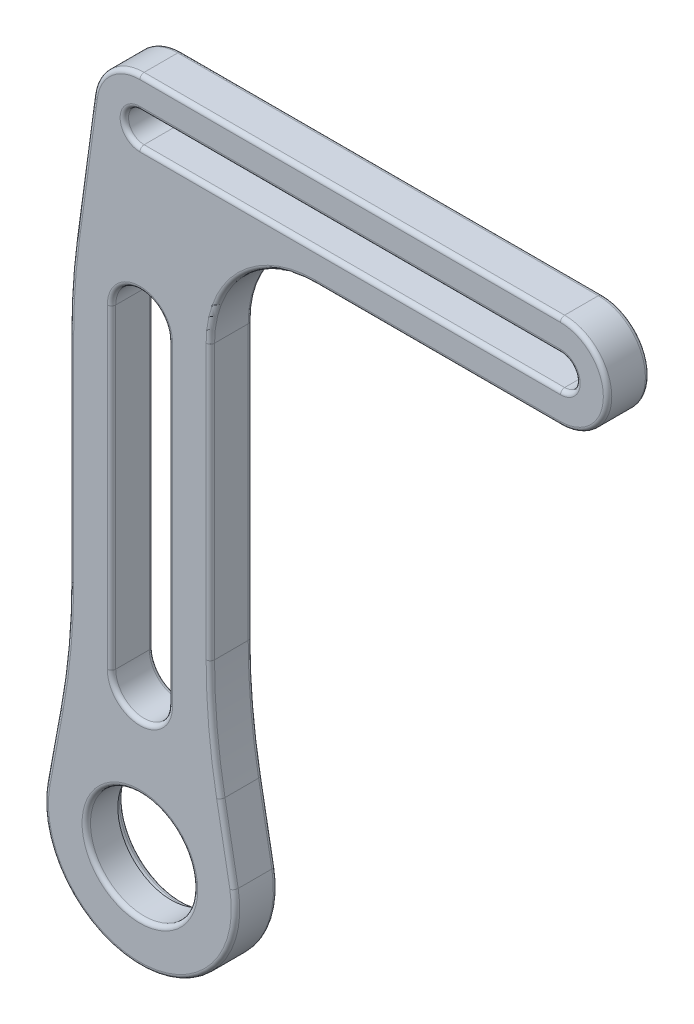
from build123d import *

# Parameters (mm, degrees)
SKETCH1_R                = 6.477
BOSS_EXTRUDE1_DEPTH      = 3.81
BOSS_EXTRUDE1_DEPTH_BACK = 1.27
SKETCH2_R                = 7.0739
CUT_EXTRUDE1_DEPTH       = 2.27
FILLET2_R                = 12.7
FILLET3_R                = 76.2
FILLET1_R                = 0.508


with BuildPart() as part:
    # Sketch1 → Boss-Extrude1 (new body, two sides)
    with BuildSketch(Plane.XY) as boss_extrude1_sk:
        with BuildLine():
            Line((-19.304, 30.32662374), (-19.304, -7.77337626))
            Line((-19.304, -7.77337626), (-22.161362566, -23.309533302))
            ThreePointArc((-22.161362566, -23.309533302), (-10.795, -36.957), (0.571362566, -23.309533302))
            Line((0.571362566, -23.309533302), (-2.286, -7.77337626))
            Line((-2.286, -7.77337626), (-2.286, 30.32662374))
            Line((-2.286, 30.32662374), (-2.286, 44.9973954))
            Line((-2.286, 44.9973954), (40.005, 44.9973954))
            ThreePointArc((40.005, 44.9973954), (45.6946, 50.6869954), (40.005, 56.3765954))
            Line((40.005, 56.3765954), (-10.795, 56.3765954))
            ThreePointArc((-10.795, 56.3765954), (-14.537468296, 54.972491779), (-16.432772192, 51.45320221))
            Line((-16.432772192, 51.45320221), (-19.304, 30.32662374))
        make_face()
        with Locations((-10.795, -25.4)):
            Circle(SKETCH1_R, mode=Mode.SUBTRACT)
        with BuildLine():
            ThreePointArc((-7.366, -7.77337626), (-10.795, -11.20237626), (-14.224, -7.77337626))
            Line((-14.224, -7.77337626), (-14.224, 30.32662374))
            ThreePointArc((-14.224, 30.32662374), (-10.795, 33.75562374), (-7.366, 30.32662374))
            Line((-7.366, 30.32662374), (-7.366, -7.77337626))
        make_face(mode=Mode.SUBTRACT)
        with BuildLine():
            ThreePointArc((-10.795, 48.8073954), (-12.6746, 50.6869954), (-10.795, 52.5665954))
            Line((-10.795, 52.5665954), (40.005, 52.5665954))
            ThreePointArc((40.005, 52.5665954), (41.8846, 50.6869954), (40.005, 48.8073954))
            Line((40.005, 48.8073954), (-10.795, 48.8073954))
        make_face(mode=Mode.SUBTRACT)
    extrude(amount=BOSS_EXTRUDE1_DEPTH)
    extrude(boss_extrude1_sk.sketch, amount=-BOSS_EXTRUDE1_DEPTH_BACK)

    # Sketch2 → Cut-Extrude1 (cut, through all)
    with BuildSketch(Plane.XY):
        with Locations((-10.795, -25.4)):
            Circle(SKETCH2_R)
    extrude(amount=-CUT_EXTRUDE1_DEPTH, mode=Mode.SUBTRACT)

    # Fillet2
    fillet2_edges = [part.edges().sort_by_distance(p)[0] for p in [
        (-2.286, 44.9973954, 1.27),
    ]]
    fillet(fillet2_edges, radius=FILLET2_R)

    # Fillet3
    fillet3_edges = [part.edges().sort_by_distance(p)[0] for p in [
        (-2.286, -7.77337626, 1.27),
        (-19.304, -7.77337626, 1.27),
        (-19.304, 30.32662374, 1.27),
    ]]
    fillet(fillet3_edges, radius=FILLET3_R)

    # Fillet1
    fillet1_edges = [part.edges().sort_by_distance(p)[0] for p in [
        (45.6946, 50.6869954, -1.27),
        (-17.8689, -25.4, -1.27),
        (25.2095, 44.9973954, 3.81),
        (25.2095, 44.9973954, -1.27),
        (1.433743879, 41.277651521, 3.81),
        (1.433743879, 41.277651521, -1.27),
        (-0.22884366, -18.958622519, 3.81),
        (-0.22884366, -18.958622519, -1.27),
        (-2.286, 15.736490286, -1.27),
        (-2.286, 15.736490286, 3.81),
        (-19.304, 12.173941902, 3.81),
        (-19.304, 12.173941902, -1.27),
        (-21.36115634, -18.958622519, 3.81),
        (-21.36115634, -18.958622519, -1.27),
        (-17.521324879, 43.443599594, 3.81),
        (-17.521324879, 43.443599594, -1.27),
        (-19.130271349, 30.314872376, 3.81),
        (-19.130271349, 30.314872376, -1.27),
        (-1.971111851, -7.744660438, 3.81),
        (-1.971111851, -7.744660438, -1.27),
        (-19.618888149, -7.744660438, 3.81),
        (-19.618888149, -7.744660438, -1.27),
        (-10.795, 33.75562374, -1.27),
        (-7.366, 11.27662374, -1.27),
        (-10.795, -11.20237626, -1.27),
        (-14.224, 11.27662374, -1.27),
        (41.8846, 50.6869954, -1.27),
        (14.605, 48.8073954, -1.27),
        (-12.6746, 50.6869954, -1.27),
        (14.605, 52.5665954, -1.27),
        (14.605, 56.3765954, 3.81),
        (14.605, 56.3765954, -1.27),
        (41.8846, 50.6869954, 3.81),
        (14.605, 48.8073954, 3.81),
        (-12.6746, 50.6869954, 3.81),
        (-10.795, 33.75562374, 3.81),
        (-7.366, 11.27662374, 3.81),
        (-10.795, -11.20237626, 3.81),
        (-14.537468296, 54.972491779, -1.27),
        (-17.272, -25.4, 3.81),
        (-14.224, 11.27662374, 3.81),
        (14.605, 52.5665954, 3.81),
        (-14.537468296, 54.972491779, 3.81),
        (-10.795, -36.957, 3.81),
        (45.6946, 50.6869954, 3.81),
        (-10.795, -36.957, -1.27),
    ]]
    fillet(fillet1_edges, radius=FILLET1_R)


solid = part.part
